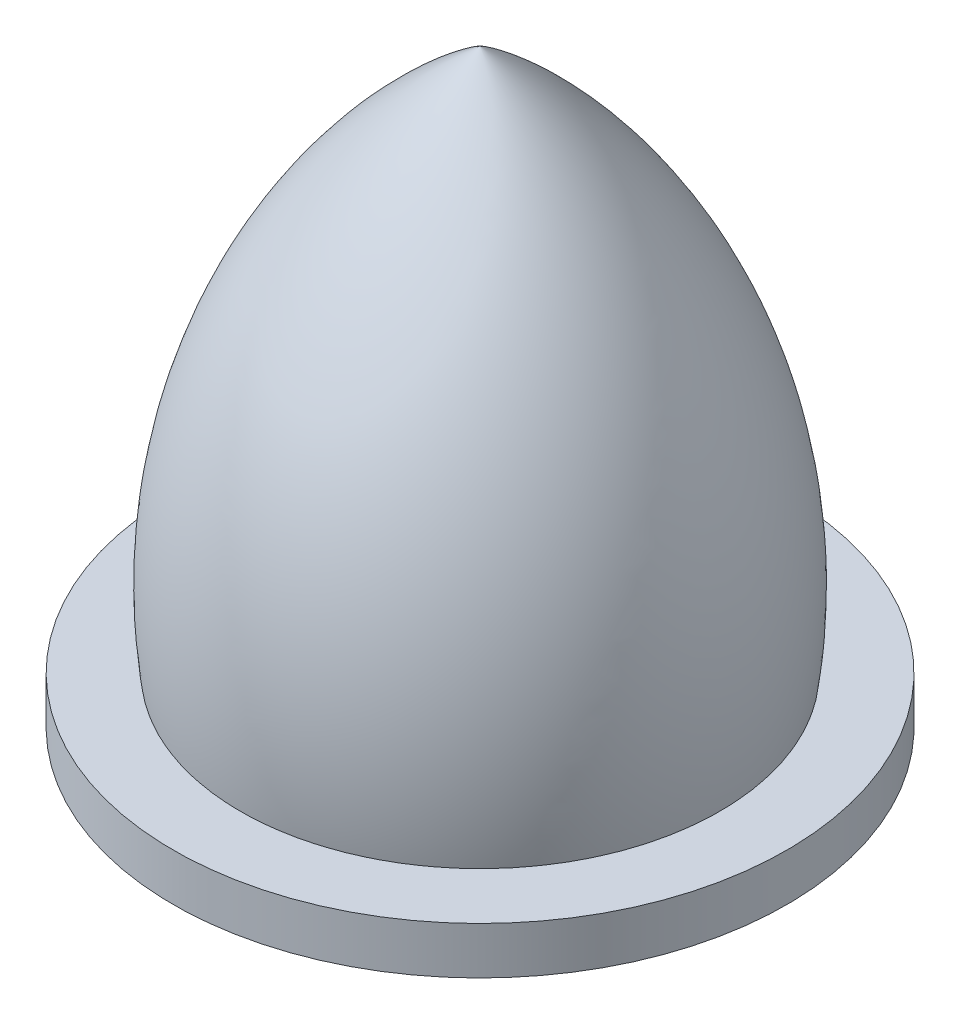
from build123d import *

# Parameters (mm, degrees)
CROQUIS2_R              = 6.5
CROQUIS2_R_2            = 5
SALIENTE_EXTRUIR1_DEPTH = 0.5
CROQUIS3_R              = 1.55
CORTAR_EXTRUIR1_DEPTH   = 4


with BuildPart() as part:
    # Croquis1 → Revolución1 (revolve)
    with BuildSketch(Plane.XY):
        with BuildLine():
            Line((0, 0), (-5, 0))
            ThreePointArc((-5, 0), (-4.265734922, 6.735722884), (0, 12))
            Line((0, 12), (0, 0))
        make_face()
    revolve(axis=Axis((0, 0, 0), (0, 1, 0)))

    # Croquis3 → Cortar-Extruir1 (cut)
    with BuildSketch(Plane.XZ):
        Circle(CROQUIS3_R)
    extrude(amount=-CORTAR_EXTRUIR1_DEPTH, mode=Mode.SUBTRACT)


with BuildPart() as body_2:
    # Croquis2 → Saliente-Extruir1 (new body, symmetric)
    with BuildSketch(Plane.XZ):
        Circle(CROQUIS2_R)
        Circle(CROQUIS2_R_2, mode=Mode.SUBTRACT)
    extrude(amount=SALIENTE_EXTRUIR1_DEPTH, both=True)


solid = Compound([part.part, body_2.part])
